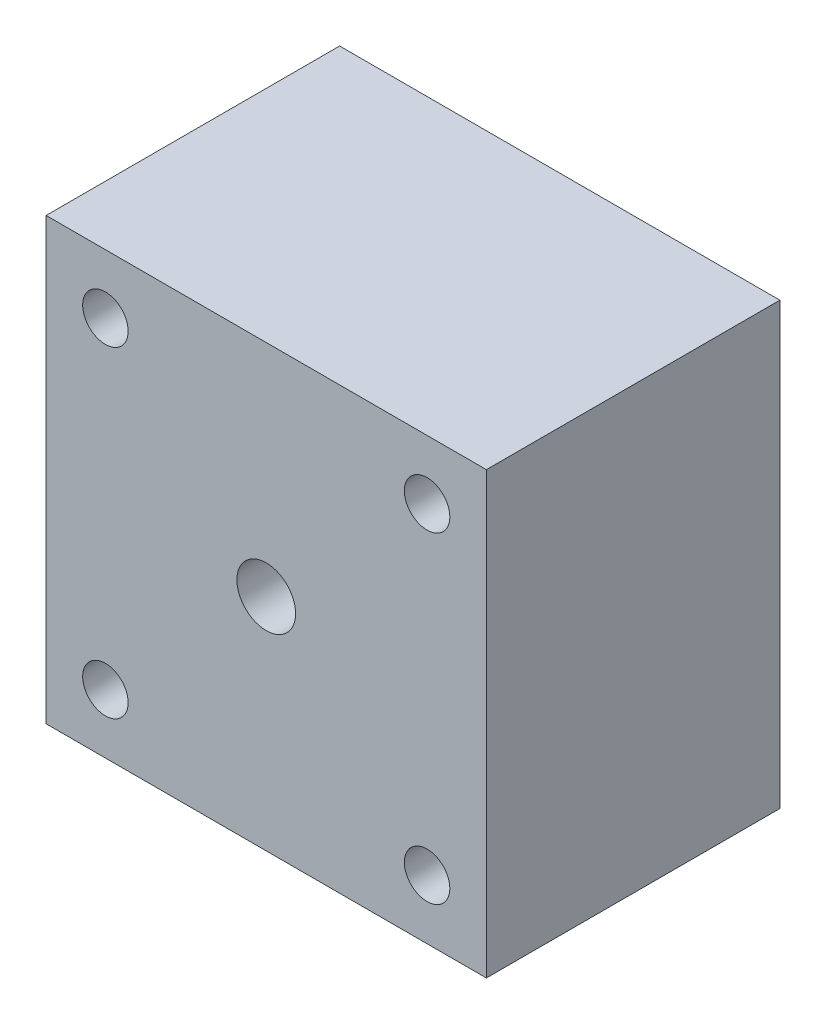
from build123d import *

# Parameters (mm, degrees)
SKETCH1_W           = 30
SKETCH1_H           = 30
SKETCH1_R           = 1.55
BOSS_EXTRUDE1_DEPTH = 20
SKETCH3_R           = 2
CUT_EXTRUDE1_DEPTH  = 10


with BuildPart() as part:
    # Sketch1 → Boss-Extrude1 (new body)
    with BuildSketch(Plane.XY):
        Rectangle(SKETCH1_W, SKETCH1_H)
        with Locations((-10.960155108, 10.960155108)):
            Circle(SKETCH1_R, mode=Mode.SUBTRACT)
        with Locations((10.960155108, 10.960155108)):
            Circle(SKETCH1_R, mode=Mode.SUBTRACT)
        with Locations((10.960155108, -10.960155108)):
            Circle(SKETCH1_R, mode=Mode.SUBTRACT)
        with Locations((-10.960155108, -10.960155108)):
            Circle(SKETCH1_R, mode=Mode.SUBTRACT)
    extrude(amount=BOSS_EXTRUDE1_DEPTH)

    # Sketch3 → Cut-Extrude1 (cut)
    with BuildSketch(Plane.XY.offset(20)):
        Circle(SKETCH3_R)
    extrude(amount=-CUT_EXTRUDE1_DEPTH, mode=Mode.SUBTRACT)


solid = part.part
